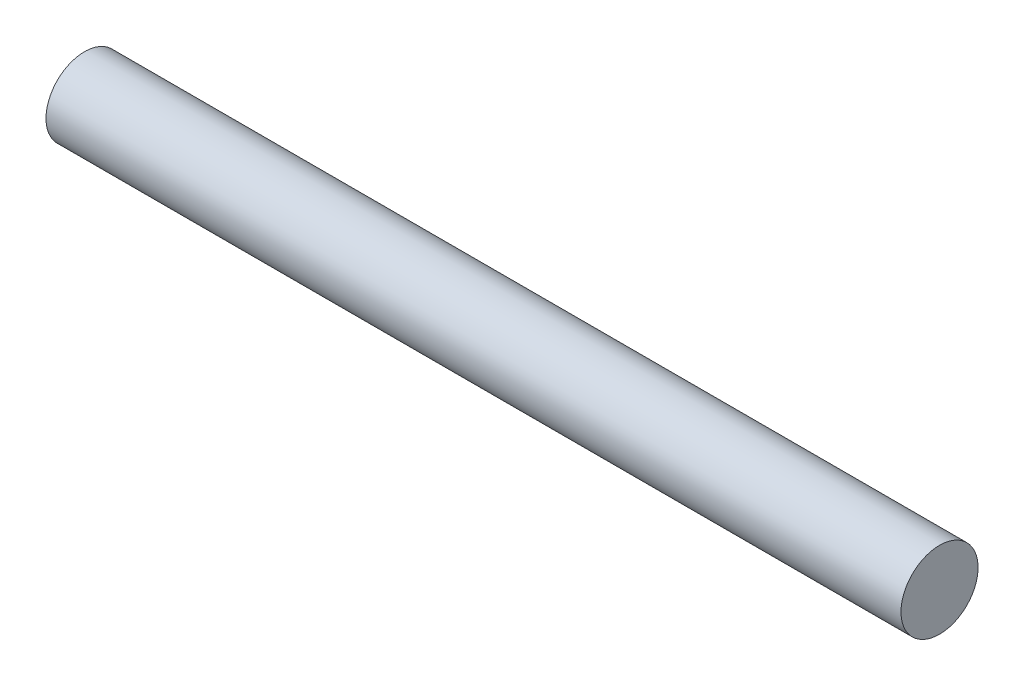
from build123d import *

# Parameters (mm, degrees)
SKETCH1_W = 53.575
SKETCH1_H = 2.415


with BuildPart() as part:
    # Sketch1 → Revolve1 (revolve)
    with BuildSketch(Plane.XY):
        with Locations((-1.460798996, 1.2075)):
            Rectangle(SKETCH1_W, SKETCH1_H)
    revolve(axis=Axis((-28.248298996, 0, 0), (1, 0, 0)))


solid = part.part
